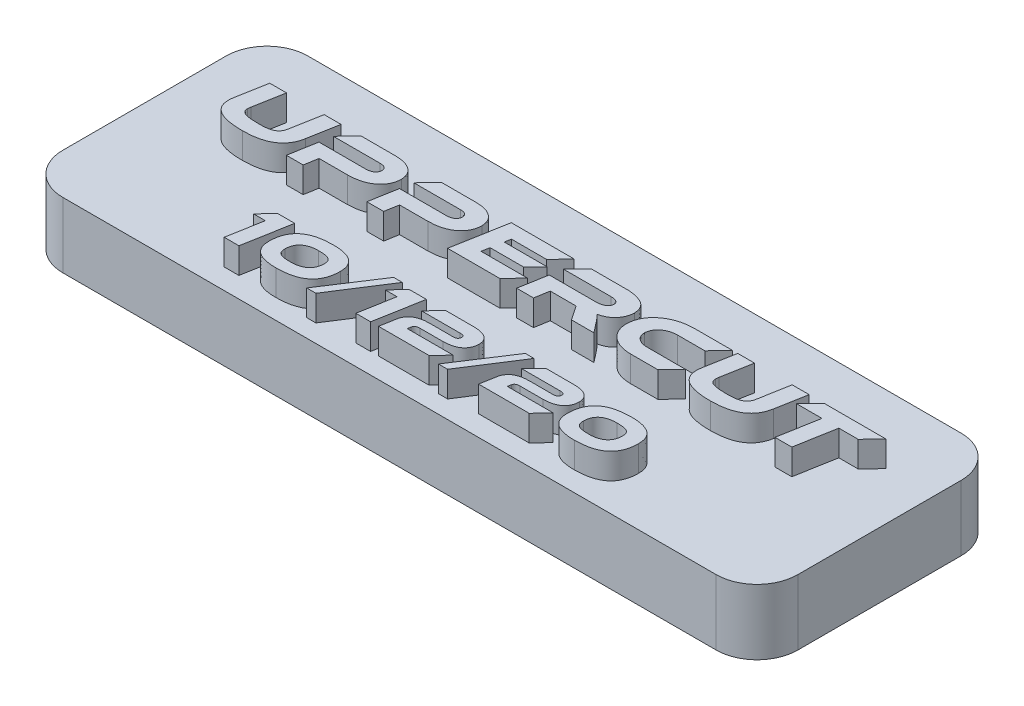
from build123d import *

# Parameters (mm, degrees)
SKETCH1_W           = 57.15
SKETCH1_H           = 19.05
BOSS_EXTRUDE1_DEPTH = 5.08
FILLET1_R           = 3.175
BOSS_EXTRUDE2_DEPTH = 2
SKETCH4_R           = 0.9
CUT_EXTRUDE1_DEPTH  = 4


with BuildPart() as part:
    # Sketch1 → Boss-Extrude1 (new body)
    with BuildSketch(Plane(origin=(0, 0, 0), x_dir=(1, 0, 0), z_dir=(0, 1, 0))):
        Rectangle(SKETCH1_W, SKETCH1_H)
    extrude(amount=BOSS_EXTRUDE1_DEPTH)

    # Fillet1
    fillet1_edges = [part.edges().sort_by_distance(p)[0] for p in [
        (-28.575, 2.54, -9.525),
        (-28.575, 2.54, 9.525),
        (28.575, 2.54, 9.525),
        (28.575, 2.54, -9.525),
    ]]
    fillet(fillet1_edges, radius=FILLET1_R)

    # Sketch3 → Boss-Extrude2 (add)
    with BuildSketch(Plane(origin=(0, 5.08, 0), x_dir=(1, 0, 0), z_dir=(0, 1, 0))):
        Polygon((20.057249805, 4.206347541), (19.008339545, 3.106887389), (20.992422808, 3.106887389), (20.442692732, 0.003655726), (21.750671189, 0.003655726), (22.306720002, 3.106887389), (23.81057929, 3.106887389), (24.859489551, 4.206347541), align=None)
        with BuildLine():
            Line((18.891658067, 4.208766837), (17.577360874, 4.208766837))
            Line((17.577360874, 4.208766837), (17.154005528, 1.862388219))
            add(Edge.make_bspline(
                [(17.154005528, 1.862388219), (17.147281003, 1.827139312), (17.134248218, 1.758823487), (17.105926854, 1.660431879), (17.068621458, 1.570400798), (17.023293564, 1.487363307), (16.969370817, 1.412619114), (16.907483251, 1.344995689), (16.837389946, 1.285307175), (16.758784575, 1.232427909), (16.668968149, 1.187314428), (16.567464703, 1.147991514), (16.452353726, 1.116850242), (16.324747142, 1.090400749), (16.184055726, 1.069568326), (16.030261081, 1.055333672), (15.863418631, 1.047035371), (15.747846354, 1.046819269), (15.687806908, 1.046707005)],
                knots=[0, 0, 0, 0, 0.000107621, 0.000208581, 0.000306536, 0.000399412, 0.000491759, 0.000582339, 0.000673759, 0.000767316, 0.000865846, 0.000974664, 0.001093329, 0.001223132, 0.001365473, 0.001519746, 0.001686326, 0.001866423, 0.001866423, 0.001866423, 0.001866423], degree=3))
            add(Edge.make_bspline(
                [(15.687806908, 1.046707005), (15.61954421, 1.046621121), (15.488478213, 1.046456221), (15.300132462, 1.052429953), (15.128091901, 1.060533552), (14.972635655, 1.075472065), (14.833856541, 1.093422131), (14.711141352, 1.114517759), (14.605260507, 1.141999094), (14.513870158, 1.172526408), (14.436639359, 1.209629908), (14.370477918, 1.251845467), (14.315118863, 1.30043275), (14.270329104, 1.354972316), (14.236848769, 1.415773277), (14.213717712, 1.4824615), (14.201939896, 1.555465653), (14.202181347, 1.605828027), (14.2023057, 1.631765942)],
                knots=[0, 0, 0, 0, 0.000204773, 0.000393168, 0.000565272, 0.000721365, 0.000861515, 0.000985061, 0.001094592, 0.001189417, 0.001273644, 0.00135098, 0.001424164, 0.001493694, 0.001561619, 0.001631293, 0.001704482, 0.001782207, 0.001782207, 0.001782207, 0.001782207], degree=3))
            add(Edge.make_bspline(
                [(14.2023057, 1.631765942), (14.203167723, 1.668081018), (14.204999275, 1.745240135), (14.215790586, 1.821673195), (14.221502947, 1.862132899)],
                knots=[0, 0, 0, 0, 0.00010888, 0.00023134, 0.00023134, 0.00023134, 0.00023134], degree=3))
            Line((14.221502947, 1.862132899), (14.651785871, 4.208766837))
            Line((14.651785871, 4.208766837), (13.343807414, 4.208766837))
            Line((13.343807414, 4.208766837), (12.920452068, 1.862388219))
            add(Edge.make_bspline(
                [(12.920452068, 1.862388219), (12.909111005, 1.795424142), (12.887107618, 1.665503639), (12.883846658, 1.533787249), (12.882266473, 1.46996058)],
                knots=[0, 0, 0, 0, 0.000203453, 0.00039473, 0.00039473, 0.00039473, 0.00039473], degree=3))
            add(Edge.make_bspline(
                [(12.882266473, 1.46996058), (12.883465426, 1.40859245), (12.885799793, 1.289108399), (12.915019258, 1.115562884), (12.96287782, 0.953539335), (13.032605557, 0.803554728), (13.121544547, 0.665184035), (13.232298652, 0.540177804), (13.361331831, 0.425561456), (13.51198711, 0.324145254), (13.68323014, 0.234151547), (13.877038275, 0.15809302), (14.092499451, 0.09238014), (14.330651407, 0.039293588), (14.590705654, -0.002721651), (14.873111411, -0.030740825), (15.177758859, -0.049583047), (15.38854257, -0.051848282), (15.497662754, -0.053020966)],
                knots=[0, 0, 0, 0, 0.000183929, 0.000358111, 0.000526139, 0.000689333, 0.000852629, 0.001017828, 0.001188792, 0.001369069, 0.001561259, 0.001768019, 0.001992702, 0.002236425, 0.002499429, 0.002782504, 0.003087466, 0.003414796, 0.003414796, 0.003414796, 0.003414796], degree=3))
            add(Edge.make_bspline(
                [(15.497662754, -0.053020966), (15.604662871, -0.051404013), (15.812820383, -0.0482584), (16.115843663, -0.025020937), (16.401102472, 0.011650769), (16.668347523, 0.064516757), (16.917764512, 0.131877218), (17.149339744, 0.213665603), (17.362415881, 0.311958663), (17.558152325, 0.424179889), (17.735704839, 0.552059501), (17.896087712, 0.694108361), (18.037551082, 0.852282745), (18.160504477, 1.025501425), (18.266621399, 1.21259616), (18.351802821, 1.415894135), (18.422900101, 1.632639003), (18.452605292, 1.784635018), (18.467751014, 1.862132899)],
                knots=[0, 0, 0, 0, 0.000320974, 0.000624421, 0.000911183, 0.001183331, 0.001441019, 0.001685636, 0.00191919, 0.002144039, 0.002361465, 0.002574487, 0.002785536, 0.002996585, 0.003210663, 0.003429366, 0.003656887, 0.00389357, 0.00389357, 0.00389357, 0.00389357], degree=3))
            Line((18.467751014, 1.862132899), (18.891658067, 4.208766837))
        make_face()
        with BuildLine():
            add(Edge.make_bspline(
                [(9.407795203, 1.105536066), (9.368074173, 1.106368572), (9.290658692, 1.107991107), (9.177831604, 1.120099472), (9.071586611, 1.139341634), (8.971175022, 1.164731953), (8.876642111, 1.197730851), (8.788132018, 1.237674392), (8.705834428, 1.284870974), (8.630029125, 1.338214411), (8.562557887, 1.398892985), (8.502572718, 1.463686553), (8.451815058, 1.534061863), (8.409331276, 1.609307897), (8.376494282, 1.690172386), (8.35268247, 1.775740301), (8.337908849, 1.866215268), (8.334949043, 1.928202108), (8.333433237, 1.95994744)],
                knots=[0, 0, 0, 0, 0.000119146, 0.000232213, 0.000339979, 0.000442857, 0.0005426, 0.00063997, 0.000733741, 0.000826832, 0.000917476, 0.001005473, 0.001091233, 0.001177183, 0.0012641, 0.001352376, 0.001443149, 0.001538437, 0.001538437, 0.001538437, 0.001538437], degree=3))
            add(Edge.make_bspline(
                [(8.333433237, 1.95994744), (8.335810858, 2.00089212), (8.340494794, 2.08155355), (8.364254146, 2.199187811), (8.398735013, 2.311187764), (8.445711454, 2.41754111), (8.505840054, 2.517456178), (8.577264322, 2.612420697), (8.662435349, 2.700160835), (8.757795494, 2.782047564), (8.862822624, 2.855559397), (8.974305121, 2.920673089), (9.092218027, 2.975739929), (9.215828788, 3.021270473), (9.345289436, 3.058247704), (9.480793041, 3.084423964), (9.622301031, 3.10108536), (9.718637033, 3.104537604), (9.767741787, 3.106297295)],
                knots=[0, 0, 0, 0, 0.000122909, 0.000242131, 0.000358943, 0.000473945, 0.00058996, 0.00070807, 0.000829622, 0.000956043, 0.00108463, 0.001213669, 0.001342898, 0.001474501, 0.001608483, 0.001746351, 0.001888089, 0.00203545, 0.00203545, 0.00203545, 0.00203545], degree=3))
            Line((9.767741787, 3.106297295), (11.891058651, 3.106887389))
            Line((11.891058651, 3.106887389), (12.927331438, 4.206347541))
            Line((12.927331438, 4.206347541), (9.963844016, 4.206347541))
            add(Edge.make_bspline(
                [(9.963844016, 4.206347541), (9.861824226, 4.202700375), (9.66201635, 4.195557324), (9.368800436, 4.162353327), (9.08866333, 4.110015155), (8.821802381, 4.036172143), (8.567193621, 3.945267581), (8.32606697, 3.833094278), (8.097425681, 3.702119343), (7.918513148, 3.576781715), (7.782979208, 3.469194079), (7.688901583, 3.383435035), (7.600072042, 3.295964452), (7.517272906, 3.205335074), (7.44177001, 3.110727377), (7.370584227, 3.01426649), (7.308045783, 2.913020304), (7.24987932, 2.809716549), (7.198683996, 2.702914965), (7.154840733, 2.592415367), (7.116682325, 2.479140843), (7.083139219, 2.363167205), (7.058179175, 2.243547853), (7.037481002, 2.121372678), (7.025046341, 1.99550854), (7.020951928, 1.910604524), (7.018878937, 1.867617826)],
                knots=[0, 0, 0, 0, 0.000306166, 0.000599632, 0.000884344, 0.001160233, 0.001429449, 0.00169448, 0.001956971, 0.002218938, 0.002348999, 0.002475859, 0.002600617, 0.002722926, 0.00284385, 0.002963619, 0.003082322, 0.003200591, 0.003319167, 0.003437316, 0.003556997, 0.003677669, 0.003799234, 0.003923371, 0.004049262, 0.004178365, 0.004178365, 0.004178365, 0.004178365], degree=3))
            add(Edge.make_bspline(
                [(7.018878937, 1.867617826), (7.021878811, 1.801688472), (7.02778377, 1.671912941), (7.058234277, 1.482185543), (7.106887393, 1.301387781), (7.173693671, 1.130003576), (7.258701949, 0.967607666), (7.361235998, 0.814264123), (7.483488254, 0.671011828), (7.621719522, 0.536982875), (7.775976027, 0.415938203), (7.943535418, 0.308972587), (8.124241292, 0.218224767), (8.318471195, 0.144692398), (8.524641073, 0.084618858), (8.744475973, 0.042789332), (8.976544208, 0.013380635), (9.135967459, 0.00815489), (9.217420725, 0.005484928)],
                knots=[0, 0, 0, 0, 0.000197872, 0.000389491, 0.000575101, 0.000758611, 0.000940158, 0.001123976, 0.001310786, 0.001504088, 0.001700684, 0.001897981, 0.00209953, 0.002306142, 0.002520237, 0.002742905, 0.002976823, 0.003221191, 0.003221191, 0.003221191, 0.003221191], degree=3))
            Line((9.217420725, 0.005484928), (11.341328575, 0.006075914))
            Line((11.341328575, 0.006075914), (12.371282625, 1.105536066))
            Line((12.371282625, 1.105536066), (9.407795203, 1.105536066))
        make_face()
        with BuildLine():
            add(Edge.make_bspline(
                [(5.727116011, 0.821261664), (5.699329886, 0.855514425), (5.646420316, 0.920737585), (5.572634975, 1.014147602), (5.50403179, 1.094728322), (5.443665698, 1.165931133), (5.387684564, 1.228233858), (5.336180188, 1.283693514), (5.287597305, 1.332710365), (5.25529343, 1.361916294), (5.239934106, 1.375802657)],
                knots=[0, 0, 0, 0, 0.000132319, 0.000251958, 0.000357066, 0.000449775, 0.000531993, 0.000608312, 0.000676831, 0.00073894, 0.00073894, 0.00073894, 0.00073894], degree=3))
            add(Edge.make_bspline(
                [(5.239934106, 1.375802657), (5.290379029, 1.387655917), (5.389711739, 1.41099655), (5.533678759, 1.456505146), (5.66951749, 1.512656797), (5.797487033, 1.577599655), (5.918273639, 1.650662326), (6.029998059, 1.734287933), (6.133735938, 1.827209607), (6.229291405, 1.928008098), (6.315158221, 2.036209783), (6.391371829, 2.148795776), (6.454618099, 2.26744033), (6.508284043, 2.389702633), (6.548786426, 2.517720245), (6.580940206, 2.649747841), (6.598549901, 2.787111939), (6.602681344, 2.88015474), (6.604766908, 2.927122995)],
                knots=[0, 0, 0, 0, 0.000155422, 0.000306047, 0.000452383, 0.000595882, 0.000736201, 0.000875336, 0.001013884, 0.001153561, 0.001291475, 0.00142788, 0.00156081, 0.001694289, 0.00182785, 0.001963107, 0.002101444, 0.002242464, 0.002242464, 0.002242464, 0.002242464], degree=3))
            add(Edge.make_bspline(
                [(6.604766908, 2.927122995), (6.600103261, 2.986733362), (6.591104301, 3.101757358), (6.554698133, 3.266295736), (6.502112492, 3.416602664), (6.431151028, 3.55250609), (6.342622808, 3.674215745), (6.234821065, 3.779555576), (6.111475526, 3.872802597), (5.969843767, 3.946152329), (5.820050119, 4.009923214), (5.665760749, 4.066098529), (5.507642934, 4.111445148), (5.346655301, 4.149301444), (5.182087966, 4.17747869), (5.014545727, 4.196572697), (4.843938234, 4.207081738), (4.729239675, 4.20637971), (4.671329952, 4.206025266)],
                knots=[0, 0, 0, 0, 0.000179195, 0.000345775, 0.000503934, 0.000655634, 0.000804102, 0.000953423, 0.00110627, 0.001266195, 0.001430402, 0.00159465, 0.001758393, 0.001923592, 0.002090563, 0.002258951, 0.002429281, 0.002602973, 0.002602973, 0.002602973, 0.002602973], degree=3))
            Line((4.671329952, 4.206025266), (1.954830316, 4.206347541))
            Line((1.954830316, 4.206347541), (0.905920056, 3.106887389))
            Line((0.905920056, 3.106887389), (4.583424704, 3.106887389))
            add(Edge.make_bspline(
                [(4.583424704, 3.106887389), (4.631386254, 3.105563142), (4.72219801, 3.103055777), (4.850302821, 3.084102014), (4.961923114, 3.053127658), (5.056282687, 3.008361144), (5.132449006, 2.950733271), (5.188185418, 2.878524615), (5.221412081, 2.792039639), (5.225177429, 2.729960255), (5.227135942, 2.697670193)],
                knots=[0, 0, 0, 0, 0.000143839, 0.000272348, 0.000387495, 0.000490117, 0.000583924, 0.00067132, 0.000760449, 0.00085706, 0.00085706, 0.00085706, 0.00085706], degree=3))
            add(Edge.make_bspline(
                [(5.227135942, 2.697670193), (5.225458902, 2.677195647), (5.222150911, 2.636809238), (5.209369674, 2.578009425), (5.189261196, 2.522994029), (5.161870255, 2.47158108), (5.128478879, 2.423095084), (5.086541945, 2.378841184), (5.037523809, 2.338813063), (4.963845594, 2.288346001), (4.859231216, 2.236864834), (4.721752039, 2.191707585), (4.571146602, 2.165412454), (4.466661677, 2.161339559), (4.412624203, 2.15923314)],
                knots=[0, 0, 0, 0, 6.1582e-05, 0.000121471, 0.000179891, 0.000236731, 0.000295819, 0.000355966, 0.000418937, 0.000485369, 0.000623551, 0.000766937, 0.000918284, 0.001080402, 0.001080402, 0.001080402, 0.001080402], degree=3))
            Line((4.412624203, 2.15923314), (0.735314171, 2.159459893))
            Line((0.735314171, 2.159459893), (0.35618998, 0.003655726))
            Line((0.35618998, 0.003655726), (1.664168437, 0.003655726))
            Line((1.664168437, 0.003655726), (1.860049269, 1.11686837))
            Line((1.860049269, 1.11686837), (3.869407478, 1.11686837))
            Line((3.869407478, 1.11686837), (4.615018386, 0.003655726))
            Line((4.615018386, 0.003655726), (6.365308399, 0.003655726))
            Line((6.365308399, 0.003655726), (5.727116011, 0.821261664))
        make_face()
        Polygon((-3.50985548, 1.105536066), (-3.408755696, 1.700326644), (-0.805436255, 1.700326644), (0.104461802, 2.629107706), (-3.238149811, 2.629107706), (-3.149687499, 3.106887389), (-0.413674592, 3.106887389), (0.628916932, 4.206347541), (-4.261785125, 4.206347541), (-5.013714769, 0.006075914), (-0.944448458, 0.006075914), (0.091824329, 1.105536066), align=None)
        with BuildLine():
            add(Edge.make_bspline(
                [(-5.201539614, 2.8527417), (-5.203171033, 2.90231375), (-5.206377568, 2.999746992), (-5.230126313, 3.14197663), (-5.266185061, 3.277108946), (-5.31750117, 3.404564931), (-5.385252325, 3.52306029), (-5.466266126, 3.634253816), (-5.560915861, 3.738655138), (-5.671194718, 3.833025271), (-5.793987305, 3.919798167), (-5.931080963, 3.99434896), (-6.08084461, 4.058920389), (-6.244442992, 4.110009865), (-6.420211472, 4.152486481), (-6.609139471, 4.182135489), (-6.811028504, 4.200187529), (-6.949975131, 4.204039197), (-7.021621401, 4.206025266)],
                knots=[0, 0, 0, 0, 0.000148656, 0.000292181, 0.000431448, 0.000567592, 0.000703091, 0.000839863, 0.000979636, 0.0011248, 0.001274431, 0.001429905, 0.001592071, 0.00176293, 0.001943415, 0.002134132, 0.002336075, 0.002551059, 0.002551059, 0.002551059, 0.002551059], degree=3))
            Line((-7.021621401, 4.206025266), (-9.675205061, 4.206347541))
            Line((-9.675205061, 4.206347541), (-10.736752794, 3.106887389))
            Line((-10.736752794, 3.106887389), (-7.097160566, 3.106887389))
            add(Edge.make_bspline(
                [(-7.097160566, 3.106887389), (-7.053918462, 3.105271439), (-6.972597974, 3.102232508), (-6.858329579, 3.082562512), (-6.76022204, 3.049448147), (-6.678912445, 3.002533217), (-6.615151208, 2.944054673), (-6.568510631, 2.875128596), (-6.54006583, 2.795454755), (-6.536913202, 2.738736187), (-6.535291159, 2.709554203)],
                knots=[0, 0, 0, 0, 0.000129715, 0.000243941, 0.000346575, 0.000438764, 0.000523505, 0.000603877, 0.000686278, 0.000773603, 0.000773603, 0.000773603, 0.000773603], degree=3))
            add(Edge.make_bspline(
                [(-6.535291159, 2.709554203), (-6.536101277, 2.68940885), (-6.537680837, 2.650129607), (-6.546894816, 2.592714955), (-6.562425767, 2.538325425), (-6.584720059, 2.486997986), (-6.612016173, 2.438376615), (-6.64545537, 2.39293274), (-6.685147056, 2.350727054), (-6.746624847, 2.297975724), (-6.837650292, 2.241909704), (-6.964950412, 2.194774305), (-7.110410363, 2.164290223), (-7.214038019, 2.160374672), (-7.26844314, 2.158318986)],
                knots=[0, 0, 0, 0, 6.0445e-05, 0.000117855, 0.000173984, 0.00022968, 0.000285354, 0.000340937, 0.0003985, 0.000458785, 0.000583594, 0.000716696, 0.00086425, 0.001027338, 0.001027338, 0.001027338, 0.001027338], degree=3))
            Line((-7.26844314, 2.158318986), (-10.90735868, 2.158641261))
            Line((-10.90735868, 2.158641261), (-11.28648287, 0.003655726))
            Line((-11.28648287, 0.003655726), (-9.98482315, 0.003655726))
            Line((-9.98482315, 0.003655726), (-9.795261054, 1.059182001))
            Line((-9.795261054, 1.059182001), (-7.583703277, 1.059182001))
            add(Edge.make_bspline(
                [(-7.583703277, 1.059182001), (-7.49346828, 1.061335988), (-7.317746449, 1.065530619), (-7.062379478, 1.093356204), (-6.821270554, 1.132182566), (-6.595931648, 1.189220643), (-6.384588635, 1.259358952), (-6.188669574, 1.345243266), (-6.007477349, 1.445895761), (-5.84262085, 1.561391424), (-5.694686351, 1.688577723), (-5.565839028, 1.826902301), (-5.454680607, 1.973467635), (-5.364889314, 2.131094192), (-5.293673948, 2.29789434), (-5.242829556, 2.47443279), (-5.209911336, 2.660218917), (-5.2043632, 2.787424299), (-5.201539614, 2.8527417)],
                knots=[0, 0, 0, 0, 0.000270666, 0.000527089, 0.000769951, 0.001002752, 0.001223611, 0.001437281, 0.001643542, 0.001844398, 0.002040129, 0.002227698, 0.002410529, 0.002590701, 0.002770513, 0.002953344, 0.003140755, 0.003334978, 0.003334978, 0.003334978, 0.003334978], degree=3))
        make_face()
        with BuildLine():
            add(Edge.make_bspline(
                [(-11.461670242, 2.8527417), (-11.463301661, 2.90231375), (-11.466508196, 2.999746992), (-11.490256941, 3.14197663), (-11.526315689, 3.277108946), (-11.577631798, 3.404564931), (-11.645382953, 3.52306029), (-11.726396754, 3.634253816), (-11.821046489, 3.738655138), (-11.931325346, 3.833025271), (-12.054117933, 3.919798167), (-12.191211591, 3.99434896), (-12.340975238, 4.058920389), (-12.50457362, 4.110009865), (-12.6803421, 4.152486481), (-12.869270099, 4.182135489), (-13.071159132, 4.200187529), (-13.210105759, 4.204039197), (-13.281752029, 4.206025266)],
                knots=[0, 0, 0, 0, 0.000148656, 0.000292181, 0.000431448, 0.000567592, 0.000703091, 0.000839863, 0.000979636, 0.0011248, 0.001274431, 0.001429905, 0.001592071, 0.00176293, 0.001943415, 0.002134132, 0.002336075, 0.002551059, 0.002551059, 0.002551059, 0.002551059], degree=3))
            Line((-13.281752029, 4.206025266), (-15.935335689, 4.206347541))
            Line((-15.935335689, 4.206347541), (-16.996883422, 3.106887389))
            Line((-16.996883422, 3.106887389), (-13.357291194, 3.106887389))
            add(Edge.make_bspline(
                [(-13.357291194, 3.106887389), (-13.31404909, 3.105271439), (-13.232728602, 3.102232508), (-13.118460207, 3.082562512), (-13.020352668, 3.049448147), (-12.939043073, 3.002533217), (-12.875281836, 2.944054673), (-12.828641259, 2.875128596), (-12.800196458, 2.795454755), (-12.79704383, 2.738736187), (-12.795421787, 2.709554203)],
                knots=[0, 0, 0, 0, 0.000129715, 0.000243941, 0.000346575, 0.000438764, 0.000523505, 0.000603877, 0.000686278, 0.000773603, 0.000773603, 0.000773603, 0.000773603], degree=3))
            add(Edge.make_bspline(
                [(-12.795421787, 2.709554203), (-12.796231905, 2.68940885), (-12.797811465, 2.650129607), (-12.807025444, 2.592714955), (-12.822556395, 2.538325425), (-12.844850687, 2.486997986), (-12.872146801, 2.438376615), (-12.905585998, 2.39293274), (-12.945277684, 2.350727054), (-13.006755475, 2.297975724), (-13.09778092, 2.241909704), (-13.22508104, 2.194774305), (-13.370540991, 2.164290223), (-13.474168647, 2.160374672), (-13.528573768, 2.158318986)],
                knots=[0, 0, 0, 0, 6.0445e-05, 0.000117855, 0.000173984, 0.00022968, 0.000285354, 0.000340937, 0.0003985, 0.000458785, 0.000583594, 0.000716696, 0.00086425, 0.001027338, 0.001027338, 0.001027338, 0.001027338], degree=3))
            Line((-13.528573768, 2.158318986), (-17.167489308, 2.158641261))
            Line((-17.167489308, 2.158641261), (-17.546613498, 0.003655726))
            Line((-17.546613498, 0.003655726), (-16.244953778, 0.003655726))
            Line((-16.244953778, 0.003655726), (-16.055391682, 1.059182001))
            Line((-16.055391682, 1.059182001), (-13.843833905, 1.059182001))
            add(Edge.make_bspline(
                [(-13.843833905, 1.059182001), (-13.753598908, 1.061335988), (-13.577877077, 1.065530619), (-13.322510106, 1.093356204), (-13.081401182, 1.132182566), (-12.856062276, 1.189220643), (-12.644719263, 1.259358952), (-12.448800202, 1.345243266), (-12.267607977, 1.445895761), (-12.102751478, 1.561391424), (-11.95481698, 1.688577723), (-11.825969656, 1.826902301), (-11.714811235, 1.973467635), (-11.625019942, 2.131094192), (-11.553804576, 2.29789434), (-11.502960184, 2.47443279), (-11.470041964, 2.660218917), (-11.464493828, 2.787424299), (-11.461670242, 2.8527417)],
                knots=[0, 0, 0, 0, 0.000270666, 0.000527089, 0.000769951, 0.001002752, 0.001223611, 0.001437281, 0.001643542, 0.001844398, 0.002040129, 0.002227698, 0.002410529, 0.002590701, 0.002770513, 0.002953344, 0.003140755, 0.003334978, 0.003334978, 0.003334978, 0.003334978], degree=3))
        make_face()
        with BuildLine():
            Line((-17.499007827, 4.208766837), (-18.81330502, 4.208766837))
            Line((-18.81330502, 4.208766837), (-19.236660366, 1.862388219))
            add(Edge.make_bspline(
                [(-19.236660366, 1.862388219), (-19.24338489, 1.827139312), (-19.256417675, 1.758823487), (-19.28473904, 1.660431879), (-19.322044435, 1.570400798), (-19.36737233, 1.487363307), (-19.421295077, 1.412619114), (-19.483182642, 1.344995689), (-19.553275948, 1.285307175), (-19.631881319, 1.232427909), (-19.721697744, 1.187314428), (-19.82320119, 1.147991514), (-19.938312168, 1.116850242), (-20.065918752, 1.090400749), (-20.206610168, 1.069568326), (-20.360404812, 1.055333672), (-20.527247262, 1.047035371), (-20.642819539, 1.046819269), (-20.702858986, 1.046707005)],
                knots=[0, 0, 0, 0, 0.000107621, 0.000208581, 0.000306536, 0.000399412, 0.000491759, 0.000582339, 0.000673759, 0.000767316, 0.000865846, 0.000974664, 0.001093329, 0.001223132, 0.001365473, 0.001519746, 0.001686326, 0.001866423, 0.001866423, 0.001866423, 0.001866423], degree=3))
            add(Edge.make_bspline(
                [(-20.702858986, 1.046707005), (-20.771121684, 1.046621121), (-20.902187681, 1.046456221), (-21.090533432, 1.052429953), (-21.262573993, 1.060533552), (-21.418030238, 1.075472065), (-21.556809353, 1.093422131), (-21.679524541, 1.114517759), (-21.785405387, 1.141999094), (-21.876795736, 1.172526408), (-21.954026535, 1.209629908), (-22.020187976, 1.251845467), (-22.075547031, 1.30043275), (-22.12033679, 1.354972316), (-22.153817124, 1.415773277), (-22.176948181, 1.4824615), (-22.188725997, 1.555465653), (-22.188484547, 1.605828027), (-22.188360193, 1.631765942)],
                knots=[0, 0, 0, 0, 0.000204773, 0.000393168, 0.000565272, 0.000721365, 0.000861515, 0.000985061, 0.001094592, 0.001189417, 0.001273644, 0.00135098, 0.001424164, 0.001493694, 0.001561619, 0.001631293, 0.001704482, 0.001782207, 0.001782207, 0.001782207, 0.001782207], degree=3))
            add(Edge.make_bspline(
                [(-22.188360193, 1.631765942), (-22.18749817, 1.668081018), (-22.185666619, 1.745240135), (-22.174875308, 1.821673195), (-22.169162947, 1.862132899)],
                knots=[0, 0, 0, 0, 0.00010888, 0.00023134, 0.00023134, 0.00023134, 0.00023134], degree=3))
            Line((-22.169162947, 1.862132899), (-21.738880023, 4.208766837))
            Line((-21.738880023, 4.208766837), (-23.04685848, 4.208766837))
            Line((-23.04685848, 4.208766837), (-23.470213826, 1.862388219))
            add(Edge.make_bspline(
                [(-23.470213826, 1.862388219), (-23.481554888, 1.795424142), (-23.503558276, 1.665503639), (-23.506819236, 1.533787249), (-23.50839942, 1.46996058)],
                knots=[0, 0, 0, 0, 0.000203453, 0.00039473, 0.00039473, 0.00039473, 0.00039473], degree=3))
            add(Edge.make_bspline(
                [(-23.50839942, 1.46996058), (-23.507200468, 1.40859245), (-23.504866101, 1.289108399), (-23.475646636, 1.115562884), (-23.427788074, 0.953539335), (-23.358060336, 0.803554728), (-23.269121347, 0.665184035), (-23.158367242, 0.540177804), (-23.029334063, 0.425561456), (-22.878678784, 0.324145254), (-22.707435754, 0.234151547), (-22.513627618, 0.15809302), (-22.298166442, 0.09238014), (-22.060014487, 0.039293588), (-21.79996024, -0.002721651), (-21.517554483, -0.030740825), (-21.212907034, -0.049583047), (-21.002123323, -0.051848282), (-20.89300314, -0.053020966)],
                knots=[0, 0, 0, 0, 0.000183929, 0.000358111, 0.000526139, 0.000689333, 0.000852629, 0.001017828, 0.001188792, 0.001369069, 0.001561259, 0.001768019, 0.001992702, 0.002236425, 0.002499429, 0.002782504, 0.003087466, 0.003414796, 0.003414796, 0.003414796, 0.003414796], degree=3))
            add(Edge.make_bspline(
                [(-20.89300314, -0.053020966), (-20.786003022, -0.051404013), (-20.577845511, -0.0482584), (-20.27482223, -0.025020937), (-19.989563421, 0.011650769), (-19.722318371, 0.064516757), (-19.472901382, 0.131877218), (-19.24132615, 0.213665603), (-19.028250013, 0.311958663), (-18.832513569, 0.424179889), (-18.654961055, 0.552059501), (-18.494578182, 0.694108361), (-18.353114812, 0.852282745), (-18.230161416, 1.025501425), (-18.124044494, 1.21259616), (-18.038863072, 1.415894135), (-17.967765793, 1.632639003), (-17.938060601, 1.784635018), (-17.922914879, 1.862132899)],
                knots=[0, 0, 0, 0, 0.000320974, 0.000624421, 0.000911183, 0.001183331, 0.001441019, 0.001685636, 0.00191919, 0.002144039, 0.002361465, 0.002574487, 0.002785536, 0.002996585, 0.003210663, 0.003429366, 0.003656887, 0.00389357, 0.00389357, 0.00389357, 0.00389357], degree=3))
            Line((-17.922914879, 1.862132899), (-17.499007827, 4.208766837))
        make_face()
        with BuildLine():
            add(Edge.make_bspline(
                [(13.500579123, -4.205753245), (13.443477767, -4.20639815), (13.331145696, -4.207666832), (13.16543427, -4.213805403), (13.005423483, -4.225246011), (12.850909879, -4.240095428), (12.702015102, -4.260037206), (12.558797757, -4.284920981), (12.420886177, -4.313802188), (12.28833715, -4.346120038), (12.161523241, -4.383749272), (12.040586014, -4.426552533), (11.924563383, -4.472224962), (11.814709109, -4.524117338), (11.709640416, -4.578873484), (11.610624121, -4.638857599), (11.517149486, -4.703243715), (11.429335476, -4.771965987), (11.346477243, -4.844826576), (11.269483602, -4.922821718), (11.197918639, -5.005043307), (11.130509006, -5.090962924), (11.070400246, -5.18251662), (11.013808375, -5.277290921), (10.964642307, -5.377585075), (10.918514335, -5.480915677), (10.87964071, -5.589719203), (10.845259992, -5.702636581), (10.81544899, -5.819692193), (10.792594038, -5.941608197), (10.773994899, -6.06752364), (10.761686051, -6.198094357), (10.753135403, -6.332815699), (10.752420947, -6.424102975), (10.752057742, -6.470510423)],
                knots=[0, 0, 0, 0, 0.000171312, 0.000337012, 0.00049738, 0.000652505, 0.000802621, 0.000947932, 0.001088493, 0.001225264, 0.001357119, 0.001485126, 0.001610044, 0.001730996, 0.001849428, 0.001965345, 0.002078058, 0.002189744, 0.002299681, 0.002408844, 0.002518253, 0.002626572, 0.002736165, 0.002846598, 0.002957491, 0.003071033, 0.00318591, 0.003303822, 0.003425073, 0.003548063, 0.003675777, 0.003806785, 0.003941403, 0.004080604, 0.004080604, 0.004080604, 0.004080604], degree=3))
            add(Edge.make_bspline(
                [(10.752057742, -6.470510423), (10.753415395, -6.532725476), (10.756049135, -6.653417738), (10.781436257, -6.827938058), (10.821959475, -6.990047106), (10.878753854, -7.14024227), (10.952699564, -7.277956037), (11.043260156, -7.403136721), (11.149590467, -7.515956622), (11.27264802, -7.616000774), (11.412134316, -7.702745849), (11.566754139, -7.779438213), (11.737866782, -7.842507446), (11.924425338, -7.895609169), (12.127240747, -7.935791135), (12.345821626, -7.964127031), (12.580330506, -7.98091947), (12.741877245, -7.982880129), (12.82536035, -7.983893345)],
                knots=[0, 0, 0, 0, 0.000186545, 0.000361882, 0.000527754, 0.000687003, 0.000842323, 0.000995285, 0.001149196, 0.001306104, 0.001469661, 0.00164101, 0.001823006, 0.002015943, 0.002222385, 0.002442644, 0.002676813, 0.00292724, 0.00292724, 0.00292724, 0.00292724], degree=3))
            add(Edge.make_bspline(
                [(12.82536035, -7.983893345), (12.882157914, -7.983380019), (12.993655983, -7.98237232), (13.158246816, -7.975990544), (13.317261471, -7.965003258), (13.471116855, -7.948680913), (13.619568795, -7.929266178), (13.762207761, -7.904105738), (13.899474511, -7.875596387), (14.030976125, -7.841995411), (14.157325378, -7.804464931), (14.27786236, -7.761989808), (14.393400638, -7.715814846), (14.503195974, -7.664606669), (14.607173984, -7.608490903), (14.706092622, -7.548339608), (14.799465438, -7.483895632), (14.887174766, -7.414499954), (14.969579615, -7.341424669), (15.045580506, -7.262809113), (15.118169189, -7.18190029), (15.183698345, -7.094705032), (15.244376696, -7.003516426), (15.300787762, -6.908219643), (15.350949963, -6.808134503), (15.395887686, -6.703993625), (15.434979148, -6.595424725), (15.469649433, -6.482622195), (15.497971449, -6.364960314), (15.522207557, -6.243348255), (15.54061351, -6.117331748), (15.552988523, -5.986773695), (15.561464444, -5.851777937), (15.562196605, -5.760225753), (15.562567729, -5.713818961)],
                knots=[0, 0, 0, 0, 0.000170392, 0.000334494, 0.000494064, 0.000648473, 0.00079859, 0.000943113, 0.001082891, 0.001219081, 0.001350169, 0.001478176, 0.001602352, 0.001723304, 0.001841405, 0.001956639, 0.002070464, 0.002181522, 0.00229199, 0.002400592, 0.0025094, 0.002617866, 0.002727459, 0.002837893, 0.002949859, 0.003063082, 0.00317796, 0.003295871, 0.003416929, 0.003540857, 0.00366778, 0.003798788, 0.003934205, 0.004073405, 0.004073405, 0.004073405, 0.004073405], degree=3))
            add(Edge.make_bspline(
                [(15.562567729, -5.713818961), (15.561226074, -5.651864372), (15.558617943, -5.53142685), (15.532905379, -5.357329546), (15.493717893, -5.194951682), (15.436692426, -5.045253766), (15.363324309, -4.907894424), (15.274069208, -4.782830639), (15.167964402, -4.670804764), (15.046343598, -4.570938519), (14.907795488, -4.484275151), (14.753605793, -4.409545186), (14.583727588, -4.345204255), (14.397800187, -4.293863202), (14.195869017, -4.25419887), (13.978407382, -4.225768444), (13.744693741, -4.209016704), (13.58367987, -4.207051109), (13.500579123, -4.205753245)],
                knots=[0, 0, 0, 0, 0.000185746, 0.000361083, 0.00052676, 0.000686009, 0.000840246, 0.000992741, 0.001145521, 0.00130181, 0.001463587, 0.001634583, 0.001815083, 0.002007802, 0.002212518, 0.002431984, 0.002665356, 0.002914983, 0.002914983, 0.002914983, 0.002914983], degree=3))
        make_face()
        with BuildLine():
            add(Edge.make_bspline(
                [(12.991920834, -7.021348599), (12.945727754, -7.021854174), (12.856573219, -7.022829956), (12.727658224, -7.017591194), (12.608312761, -7.009340097), (12.498551662, -6.995853431), (12.39828762, -6.977791428), (12.307744287, -6.954558851), (12.226405062, -6.92776808), (12.154197246, -6.89577873), (12.090205884, -6.85746675), (12.036179313, -6.809228041), (11.989609601, -6.753532905), (11.95305929, -6.688452997), (11.923924225, -6.615916979), (11.904463421, -6.534816355), (11.892151266, -6.445830998), (11.891455672, -6.383634321), (11.89109436, -6.351327518)],
                knots=[0, 0, 0, 0, 0.000138565, 0.000267436, 0.000386943, 0.000497368, 0.000599032, 0.000692348, 0.000777591, 0.00085564, 0.000928899, 0.001000308, 0.001071897, 0.001145712, 0.001223247, 0.001305698, 0.001395292, 0.001492131, 0.001492131, 0.001492131, 0.001492131], degree=3))
            add(Edge.make_bspline(
                [(11.89109436, -6.351327518), (11.892631213, -6.304070169), (11.8956213, -6.212126705), (11.91428324, -6.079013736), (11.943538683, -5.954439253), (11.985356502, -5.839274516), (12.03741413, -5.731825667), (12.102624352, -5.634468641), (12.178440222, -5.545120744), (12.266385769, -5.466071948), (12.364358845, -5.395226287), (12.472961323, -5.334487382), (12.591341859, -5.283435533), (12.718935465, -5.240941797), (12.856268436, -5.208296683), (13.003138297, -5.185693562), (13.159672515, -5.170762309), (13.267393832, -5.169135367), (13.322888986, -5.16829721)],
                knots=[0, 0, 0, 0, 0.000141763, 0.000275812, 0.0004025, 0.000524963, 0.000642655, 0.000759791, 0.000875529, 0.00099331, 0.001113634, 0.001237554, 0.001365798, 0.001499859, 0.001640517, 0.001788722, 0.001945363, 0.002111808, 0.002111808, 0.002111808, 0.002111808], degree=3))
            add(Edge.make_bspline(
                [(13.322888986, -5.16829721), (13.369017635, -5.168009724), (13.458095955, -5.167454564), (13.587246267, -5.171313587), (13.706857399, -5.17974049), (13.816794485, -5.193477036), (13.917087693, -5.210588071), (14.007799449, -5.232796313), (14.088993751, -5.25982086), (14.161278539, -5.291687778), (14.224904132, -5.330152418), (14.279299498, -5.377160874), (14.324886794, -5.432670471), (14.361811337, -5.496790682), (14.390660652, -5.569240936), (14.410087678, -5.650050065), (14.422523204, -5.738759012), (14.423185583, -5.80069376), (14.423531111, -5.833001866)],
                knots=[0, 0, 0, 0, 0.00013838, 0.000267224, 0.000387529, 0.000497953, 0.000599476, 0.000692596, 0.00077784, 0.000855889, 0.000929147, 0.001000031, 0.001070493, 0.001143616, 0.001221151, 0.001303602, 0.001392403, 0.001489242, 0.001489242, 0.001489242, 0.001489242], degree=3))
            add(Edge.make_bspline(
                [(14.423531111, -5.833001866), (14.421993591, -5.880258006), (14.419002207, -5.972199119), (14.400313372, -6.105585977), (14.370952423, -6.230260661), (14.330249758, -6.346409008), (14.277247601, -6.453739693), (14.211830339, -6.551573704), (14.136186329, -6.64153852), (14.048544329, -6.721564153), (13.950129382, -6.791879743), (13.842584497, -6.854243117), (13.724035159, -6.904835069), (13.596395026, -6.947243215), (13.459199853, -6.980841995), (13.312098289, -7.004512108), (13.15520754, -7.019068958), (13.04722791, -7.020761541), (12.991920834, -7.021348599)],
                knots=[0, 0, 0, 0, 0.000141763, 0.000275812, 0.000403278, 0.000525472, 0.000644235, 0.000761371, 0.000877718, 0.000996039, 0.001116363, 0.001239983, 0.001368227, 0.001502288, 0.001643134, 0.001791467, 0.001948904, 0.002115349, 0.002115349, 0.002115349, 0.002115349], degree=3))
        make_face(mode=Mode.SUBTRACT)
        with BuildLine():
            Line((5.969282838, -5.218973535), (8.960414732, -5.218973535))
            add(Edge.make_bspline(
                [(8.960414732, -5.218973535), (8.988115646, -5.218922741), (9.039962021, -5.218827674), (9.112691024, -5.225918073), (9.174215065, -5.242216387), (9.226045602, -5.26353583), (9.266138991, -5.294908436), (9.294452991, -5.334273792), (9.312004968, -5.381008794), (9.313229668, -5.4147712), (9.313864034, -5.432259348)],
                knots=[0, 0, 0, 0, 8.3099e-05, 0.000155531, 0.000218392, 0.000273538, 0.000322508, 0.000368908, 0.000417497, 0.000469711, 0.000469711, 0.000469711, 0.000469711], degree=3))
            add(Edge.make_bspline(
                [(9.313864034, -5.432259348), (9.31322424, -5.458018948), (9.312014636, -5.506720508), (9.29145225, -5.573936821), (9.258165874, -5.630194031), (9.208952251, -5.673414306), (9.145421152, -5.704561408), (9.067686985, -5.726311626), (8.974561826, -5.738498194), (8.907560181, -5.73961472), (8.871527482, -5.740215175)],
                knots=[0, 0, 0, 0, 7.6993e-05, 0.000145564, 0.000208395, 0.000270703, 0.000339032, 0.00041902, 0.000511893, 0.000619952, 0.000619952, 0.000619952, 0.000619952], degree=3))
            Line((8.871527482, -5.740215175), (7.113763988, -5.739416071))
            add(Edge.make_bspline(
                [(7.113763988, -5.739416071), (7.058161832, -5.740560639), (6.94990867, -5.742789025), (6.791913343, -5.753609346), (6.643193984, -5.772857955), (6.503571116, -5.798779792), (6.373307918, -5.833149331), (6.252229066, -5.875619954), (6.139961685, -5.92500466), (6.036759818, -5.98174212), (5.943290621, -6.047028209), (5.858765128, -6.120143527), (5.783364519, -6.201107035), (5.717363497, -6.289606037), (5.660981923, -6.385733808), (5.613886169, -6.489539314), (5.574938805, -6.600822081), (5.55761713, -6.678800473), (5.548804088, -6.718474855)],
                knots=[0, 0, 0, 0, 0.000166829, 0.000324804, 0.000474816, 0.000616477, 0.000750546, 0.000878553, 0.001001026, 0.001118108, 0.001231277, 0.001342418, 0.001452782, 0.001562526, 0.00167296, 0.001786425, 0.001904052, 0.002025887, 0.002025887, 0.002025887, 0.002025887], degree=3))
            Line((5.548804088, -6.718474855), (5.333459977, -7.932183575))
            Line((5.333459977, -7.932183575), (9.270032821, -7.932183575))
            Line((9.270032821, -7.932183575), (10.17677151, -6.970155942))
            Line((10.17677151, -6.970155942), (6.605105699, -6.970155942))
            Line((6.605105699, -6.970155942), (6.654865749, -6.707239748))
            add(Edge.make_bspline(
                [(6.654865749, -6.707239748), (6.658643273, -6.686112106), (6.66596603, -6.645156023), (6.694677383, -6.590591717), (6.733038076, -6.543848716), (6.784377407, -6.508043577), (6.845452874, -6.47963759), (6.917770494, -6.461031101), (7.000833915, -6.450993538), (7.059757426, -6.450679637), (7.09098288, -6.450513291)],
                knots=[0, 0, 0, 0, 6.4036e-05, 0.000124134, 0.000182613, 0.000243892, 0.000310094, 0.000383827, 0.000466868, 0.000560486, 0.000560486, 0.000560486, 0.000560486], degree=3))
            Line((7.09098288, -6.450513291), (8.849836843, -6.449714187))
            add(Edge.make_bspline(
                [(8.849836843, -6.449714187), (8.915517868, -6.448593152), (9.042852309, -6.446419826), (9.226750158, -6.426694059), (9.398166768, -6.400940141), (9.556013654, -6.361961645), (9.701767648, -6.315052912), (9.833108903, -6.255202462), (9.952582018, -6.187512089), (10.057294458, -6.107690588), (10.14987765, -6.020066732), (10.230334011, -5.925525662), (10.298112896, -5.823724541), (10.353865698, -5.715194429), (10.396001667, -5.599220599), (10.426697103, -5.476792913), (10.444352448, -5.347458364), (10.446305402, -5.259004345), (10.447301455, -5.21389067)],
                knots=[0, 0, 0, 0, 0.00019697, 0.000381861, 0.000554393, 0.000716581, 0.000869107, 0.001013024, 0.00114885, 0.001280192, 0.001406932, 0.001530654, 0.001651783, 0.001773055, 0.001895792, 0.002021116, 0.002151095, 0.002286391, 0.002286391, 0.002286391, 0.002286391], degree=3))
            add(Edge.make_bspline(
                [(10.447301455, -5.21389067), (10.446849001, -5.1780961), (10.445963256, -5.108023129), (10.429753409, -5.005989197), (10.405761336, -4.909275966), (10.369226633, -4.818686266), (10.32159228, -4.734234215), (10.263513238, -4.655338408), (10.195145611, -4.582231577), (10.115851171, -4.515185386), (10.025028254, -4.455053695), (9.921449634, -4.402688892), (9.805216513, -4.359688685), (9.677029034, -4.322394884), (9.536226025, -4.294289614), (9.38287898, -4.27367202), (9.217012449, -4.26108405), (9.102182833, -4.258543735), (9.042702929, -4.257227893)],
                knots=[0, 0, 0, 0, 0.000107259, 0.000209975, 0.000309113, 0.00040566, 0.000501999, 0.00059927, 0.000698874, 0.0008016, 0.000910084, 0.001024914, 0.001148961, 0.001281358, 0.001425053, 0.00157924, 0.00174531, 0.001923772, 0.001923772, 0.001923772, 0.001923772], degree=3))
            Line((9.042702929, -4.257227893), (6.876021527, -4.256945902))
            Line((6.876021527, -4.256945902), (5.969282838, -5.218973535))
        make_face()
        Polygon((5.083472397, -4.05005839), (2.418545275, -8.139071868), (3.131772658, -8.139071868), (5.757997519, -4.05005839), align=None)
        with BuildLine():
            Line((-1.812001027, -5.218973535), (1.179130867, -5.218973535))
            add(Edge.make_bspline(
                [(1.179130867, -5.218973535), (1.206831781, -5.218922741), (1.258678156, -5.218827674), (1.331407159, -5.225918073), (1.392931201, -5.242216387), (1.444761737, -5.26353583), (1.484855127, -5.294908436), (1.513169126, -5.334273792), (1.530721104, -5.381008794), (1.531945803, -5.4147712), (1.532580169, -5.432259348)],
                knots=[0, 0, 0, 0, 8.3099e-05, 0.000155531, 0.000218392, 0.000273538, 0.000322508, 0.000368908, 0.000417497, 0.000469711, 0.000469711, 0.000469711, 0.000469711], degree=3))
            add(Edge.make_bspline(
                [(1.532580169, -5.432259348), (1.531940376, -5.458018948), (1.530730771, -5.506720508), (1.510168385, -5.573936821), (1.476882009, -5.630194031), (1.427668386, -5.673414306), (1.364137287, -5.704561408), (1.286403121, -5.726311626), (1.193277961, -5.738498194), (1.126276316, -5.73961472), (1.090243617, -5.740215175)],
                knots=[0, 0, 0, 0, 7.6993e-05, 0.000145564, 0.000208395, 0.000270703, 0.000339032, 0.00041902, 0.000511893, 0.000619952, 0.000619952, 0.000619952, 0.000619952], degree=3))
            Line((1.090243617, -5.740215175), (-0.667519877, -5.739416071))
            add(Edge.make_bspline(
                [(-0.667519877, -5.739416071), (-0.723122033, -5.740560639), (-0.831375195, -5.742789025), (-0.989370521, -5.753609346), (-1.138089881, -5.772857955), (-1.277712749, -5.798779792), (-1.407975947, -5.833149331), (-1.529054799, -5.875619954), (-1.641322179, -5.92500466), (-1.744524047, -5.98174212), (-1.837993244, -6.047028209), (-1.922518737, -6.120143527), (-1.997919346, -6.201107035), (-2.063920368, -6.289606037), (-2.120301941, -6.385733808), (-2.167397696, -6.489539314), (-2.206345059, -6.600822081), (-2.223666735, -6.678800473), (-2.232479777, -6.718474855)],
                knots=[0, 0, 0, 0, 0.000166829, 0.000324804, 0.000474816, 0.000616477, 0.000750546, 0.000878553, 0.001001026, 0.001118108, 0.001231277, 0.001342418, 0.001452782, 0.001562526, 0.00167296, 0.001786425, 0.001904052, 0.002025887, 0.002025887, 0.002025887, 0.002025887], degree=3))
            Line((-2.232479777, -6.718474855), (-2.447823888, -7.932183575))
            Line((-2.447823888, -7.932183575), (1.488748956, -7.932183575))
            Line((1.488748956, -7.932183575), (2.395487645, -6.970155942))
            Line((2.395487645, -6.970155942), (-1.176178166, -6.970155942))
            Line((-1.176178166, -6.970155942), (-1.126418116, -6.707239748))
            add(Edge.make_bspline(
                [(-1.126418116, -6.707239748), (-1.122640592, -6.686112106), (-1.115317835, -6.645156023), (-1.086606482, -6.590591717), (-1.048245789, -6.543848716), (-0.996906457, -6.508043577), (-0.935830991, -6.47963759), (-0.863513371, -6.461031101), (-0.78044995, -6.450993538), (-0.721526439, -6.450679637), (-0.690300984, -6.450513291)],
                knots=[0, 0, 0, 0, 6.4036e-05, 0.000124134, 0.000182613, 0.000243892, 0.000310094, 0.000383827, 0.000466868, 0.000560486, 0.000560486, 0.000560486, 0.000560486], degree=3))
            Line((-0.690300984, -6.450513291), (1.068552978, -6.449714187))
            add(Edge.make_bspline(
                [(1.068552978, -6.449714187), (1.134234004, -6.448593152), (1.261568444, -6.446419826), (1.445466293, -6.426694059), (1.616882903, -6.400940141), (1.774729789, -6.361961645), (1.920483783, -6.315052912), (2.051825038, -6.255202462), (2.171298153, -6.187512089), (2.276010593, -6.107690588), (2.368593785, -6.020066732), (2.449050147, -5.925525662), (2.516829031, -5.823724541), (2.572581833, -5.715194429), (2.614717803, -5.599220599), (2.645413239, -5.476792913), (2.663068584, -5.347458364), (2.665021537, -5.259004345), (2.666017591, -5.21389067)],
                knots=[0, 0, 0, 0, 0.00019697, 0.000381861, 0.000554393, 0.000716581, 0.000869107, 0.001013024, 0.00114885, 0.001280192, 0.001406932, 0.001530654, 0.001651783, 0.001773055, 0.001895792, 0.002021116, 0.002151095, 0.002286391, 0.002286391, 0.002286391, 0.002286391], degree=3))
            add(Edge.make_bspline(
                [(2.666017591, -5.21389067), (2.665565136, -5.1780961), (2.664679391, -5.108023129), (2.648469544, -5.005989197), (2.624477471, -4.909275966), (2.587942768, -4.818686266), (2.540308415, -4.734234215), (2.482229373, -4.655338408), (2.413861747, -4.582231577), (2.334567307, -4.515185386), (2.24374439, -4.455053695), (2.140165769, -4.402688892), (2.023932649, -4.359688685), (1.895745169, -4.322394884), (1.754942161, -4.294289614), (1.601595115, -4.27367202), (1.435728584, -4.26108405), (1.320898968, -4.258543735), (1.261419064, -4.257227893)],
                knots=[0, 0, 0, 0, 0.000107259, 0.000209975, 0.000309113, 0.00040566, 0.000501999, 0.00059927, 0.000698874, 0.0008016, 0.000910084, 0.001024914, 0.001148961, 0.001281358, 0.001425053, 0.00157924, 0.00174531, 0.001923772, 0.001923772, 0.001923772, 0.001923772], degree=3))
            Line((1.261419064, -4.257227893), (-0.905262338, -4.256945902))
            Line((-0.905262338, -4.256945902), (-1.812001027, -5.218973535))
        make_face()
        Polygon((-4.623097808, -5.218973535), (-3.721888013, -5.218973535), (-4.20290183, -7.93430124), (-3.05842068, -7.93430124), (-2.400482241, -4.256945902), (-3.75506138, -4.256945902), align=None)
        Polygon((-5.155059004, -4.05005839), (-7.819986126, -8.139071868), (-7.106758743, -8.139071868), (-4.480533882, -4.05005839), align=None)
        with BuildLine():
            add(Edge.make_bspline(
                [(-9.6896945, -4.205753245), (-9.746795857, -4.20639815), (-9.859127927, -4.207666832), (-10.024839353, -4.213805403), (-10.184850141, -4.225246011), (-10.339363744, -4.240095428), (-10.488258521, -4.260037206), (-10.631475866, -4.284920981), (-10.769387446, -4.313802188), (-10.901936473, -4.346120038), (-11.028750382, -4.383749272), (-11.14968761, -4.426552533), (-11.26571024, -4.472224962), (-11.375564514, -4.524117338), (-11.480633207, -4.578873484), (-11.579649502, -4.638857599), (-11.673124137, -4.703243715), (-11.760938147, -4.771965987), (-11.84379638, -4.844826576), (-11.920790021, -4.922821718), (-11.992354985, -5.005043307), (-12.059764617, -5.090962924), (-12.119873377, -5.18251662), (-12.176465248, -5.277290921), (-12.225631317, -5.377585075), (-12.271759288, -5.480915677), (-12.310632914, -5.589719203), (-12.345013631, -5.702636581), (-12.374824633, -5.819692193), (-12.397679586, -5.941608197), (-12.416278725, -6.06752364), (-12.428587572, -6.198094357), (-12.43713822, -6.332815699), (-12.437852676, -6.424102975), (-12.438215882, -6.470510423)],
                knots=[0, 0, 0, 0, 0.000171312, 0.000337012, 0.00049738, 0.000652505, 0.000802621, 0.000947932, 0.001088493, 0.001225264, 0.001357119, 0.001485126, 0.001610044, 0.001730996, 0.001849428, 0.001965345, 0.002078058, 0.002189744, 0.002299681, 0.002408844, 0.002518253, 0.002626572, 0.002736165, 0.002846598, 0.002957491, 0.003071033, 0.00318591, 0.003303822, 0.003425073, 0.003548063, 0.003675777, 0.003806785, 0.003941403, 0.004080604, 0.004080604, 0.004080604, 0.004080604], degree=3))
            add(Edge.make_bspline(
                [(-12.438215882, -6.470510423), (-12.436858228, -6.532725476), (-12.434224488, -6.653417738), (-12.408837366, -6.827938058), (-12.368314148, -6.990047106), (-12.311519769, -7.14024227), (-12.237574059, -7.277956037), (-12.147013467, -7.403136721), (-12.040683156, -7.515956622), (-11.917625603, -7.616000774), (-11.778139308, -7.702745849), (-11.623519484, -7.779438213), (-11.452406842, -7.842507446), (-11.265848286, -7.895609169), (-11.063032876, -7.935791135), (-10.844451997, -7.964127031), (-10.609943117, -7.98091947), (-10.448396379, -7.982880129), (-10.364913273, -7.983893345)],
                knots=[0, 0, 0, 0, 0.000186545, 0.000361882, 0.000527754, 0.000687003, 0.000842323, 0.000995285, 0.001149196, 0.001306104, 0.001469661, 0.00164101, 0.001823006, 0.002015943, 0.002222385, 0.002442644, 0.002676813, 0.00292724, 0.00292724, 0.00292724, 0.00292724], degree=3))
            add(Edge.make_bspline(
                [(-10.364913273, -7.983893345), (-10.308115709, -7.983380019), (-10.19661764, -7.98237232), (-10.032026807, -7.975990544), (-9.873012152, -7.965003258), (-9.719156769, -7.948680913), (-9.570704828, -7.929266178), (-9.428065862, -7.904105738), (-9.290799112, -7.875596387), (-9.159297498, -7.841995411), (-9.032948245, -7.804464931), (-8.912411263, -7.761989808), (-8.796872986, -7.715814846), (-8.687077649, -7.664606669), (-8.583099639, -7.608490903), (-8.484181001, -7.548339608), (-8.390808185, -7.483895632), (-8.303098857, -7.414499954), (-8.220694008, -7.341424669), (-8.144693117, -7.262809113), (-8.072104434, -7.18190029), (-8.006575278, -7.094705032), (-7.945896927, -7.003516426), (-7.889485861, -6.908219643), (-7.83932366, -6.808134503), (-7.794385937, -6.703993625), (-7.755294475, -6.595424725), (-7.72062419, -6.482622195), (-7.692302174, -6.364960314), (-7.668066066, -6.243348255), (-7.649660113, -6.117331748), (-7.6372851, -5.986773695), (-7.628809179, -5.851777937), (-7.628077018, -5.760225753), (-7.627705894, -5.713818961)],
                knots=[0, 0, 0, 0, 0.000170392, 0.000334494, 0.000494064, 0.000648473, 0.00079859, 0.000943113, 0.001082891, 0.001219081, 0.001350169, 0.001478176, 0.001602352, 0.001723304, 0.001841405, 0.001956639, 0.002070464, 0.002181522, 0.00229199, 0.002400592, 0.0025094, 0.002617866, 0.002727459, 0.002837893, 0.002949859, 0.003063082, 0.00317796, 0.003295871, 0.003416929, 0.003540857, 0.00366778, 0.003798788, 0.003934205, 0.004073405, 0.004073405, 0.004073405, 0.004073405], degree=3))
            add(Edge.make_bspline(
                [(-7.627705894, -5.713818961), (-7.629047549, -5.651864372), (-7.63165568, -5.53142685), (-7.657368244, -5.357329546), (-7.69655573, -5.194951682), (-7.753581197, -5.045253766), (-7.826949314, -4.907894424), (-7.916204415, -4.782830639), (-8.022309221, -4.670804764), (-8.143930025, -4.570938519), (-8.282478135, -4.484275151), (-8.43666783, -4.409545186), (-8.606546035, -4.345204255), (-8.792473436, -4.293863202), (-8.994404606, -4.25419887), (-9.211866241, -4.225768444), (-9.445579882, -4.209016704), (-9.606593753, -4.207051109), (-9.6896945, -4.205753245)],
                knots=[0, 0, 0, 0, 0.000185746, 0.000361083, 0.00052676, 0.000686009, 0.000840246, 0.000992741, 0.001145521, 0.00130181, 0.001463587, 0.001634583, 0.001815083, 0.002007802, 0.002212518, 0.002431984, 0.002665356, 0.002914983, 0.002914983, 0.002914983, 0.002914983], degree=3))
        make_face()
        with BuildLine():
            add(Edge.make_bspline(
                [(-10.198352789, -7.021348599), (-10.244545869, -7.021854174), (-10.333700404, -7.022829956), (-10.462615399, -7.017591194), (-10.581960862, -7.009340097), (-10.691721961, -6.995853431), (-10.791986003, -6.977791428), (-10.882529336, -6.954558851), (-10.963868561, -6.92776808), (-11.036076377, -6.89577873), (-11.100067739, -6.85746675), (-11.15409431, -6.809228041), (-11.200664022, -6.753532905), (-11.237214333, -6.688452997), (-11.266349398, -6.615916979), (-11.285810202, -6.534816355), (-11.298122357, -6.445830998), (-11.298817951, -6.383634321), (-11.299179263, -6.351327518)],
                knots=[0, 0, 0, 0, 0.000138565, 0.000267436, 0.000386943, 0.000497368, 0.000599032, 0.000692348, 0.000777591, 0.00085564, 0.000928899, 0.001000308, 0.001071897, 0.001145712, 0.001223247, 0.001305698, 0.001395292, 0.001492131, 0.001492131, 0.001492131, 0.001492131], degree=3))
            add(Edge.make_bspline(
                [(-11.299179263, -6.351327518), (-11.29764241, -6.304070169), (-11.294652323, -6.212126705), (-11.275990383, -6.079013736), (-11.24673494, -5.954439253), (-11.204917121, -5.839274516), (-11.152859493, -5.731825667), (-11.087649271, -5.634468641), (-11.011833401, -5.545120744), (-10.923887854, -5.466071948), (-10.825914778, -5.395226287), (-10.7173123, -5.334487382), (-10.598931765, -5.283435533), (-10.471338158, -5.240941797), (-10.334005187, -5.208296683), (-10.187135326, -5.185693562), (-10.030601108, -5.170762309), (-9.922879791, -5.169135367), (-9.867384638, -5.16829721)],
                knots=[0, 0, 0, 0, 0.000141763, 0.000275812, 0.0004025, 0.000524963, 0.000642655, 0.000759791, 0.000875529, 0.00099331, 0.001113634, 0.001237554, 0.001365798, 0.001499859, 0.001640517, 0.001788722, 0.001945363, 0.002111808, 0.002111808, 0.002111808, 0.002111808], degree=3))
            add(Edge.make_bspline(
                [(-9.867384638, -5.16829721), (-9.821255989, -5.168009724), (-9.732177669, -5.167454564), (-9.603027356, -5.171313587), (-9.483416224, -5.17974049), (-9.373479138, -5.193477036), (-9.27318593, -5.210588071), (-9.182474175, -5.232796313), (-9.101279872, -5.25982086), (-9.028995084, -5.291687778), (-8.965369491, -5.330152418), (-8.910974125, -5.377160874), (-8.865386829, -5.432670471), (-8.828462286, -5.496790682), (-8.799612971, -5.569240936), (-8.780185946, -5.650050065), (-8.767750419, -5.738759012), (-8.76708804, -5.80069376), (-8.766742512, -5.833001866)],
                knots=[0, 0, 0, 0, 0.00013838, 0.000267224, 0.000387529, 0.000497953, 0.000599476, 0.000692596, 0.00077784, 0.000855889, 0.000929147, 0.001000031, 0.001070493, 0.001143616, 0.001221151, 0.001303602, 0.001392403, 0.001489242, 0.001489242, 0.001489242, 0.001489242], degree=3))
            add(Edge.make_bspline(
                [(-8.766742512, -5.833001866), (-8.768280032, -5.880258006), (-8.771271416, -5.972199119), (-8.789960251, -6.105585977), (-8.819321201, -6.230260661), (-8.860023865, -6.346409008), (-8.913026023, -6.453739693), (-8.978443284, -6.551573704), (-9.054087294, -6.64153852), (-9.141729294, -6.721564153), (-9.240144241, -6.791879743), (-9.347689126, -6.854243117), (-9.466238465, -6.904835069), (-9.593878597, -6.947243215), (-9.73107377, -6.980841995), (-9.878175334, -7.004512108), (-10.035066083, -7.019068958), (-10.143045714, -7.020761541), (-10.198352789, -7.021348599)],
                knots=[0, 0, 0, 0, 0.000141763, 0.000275812, 0.000403278, 0.000525472, 0.000644235, 0.000761371, 0.000877718, 0.000996039, 0.001116363, 0.001239983, 0.001368227, 0.001502288, 0.001643134, 0.001791467, 0.001948904, 0.002115349, 0.002115349, 0.002115349, 0.002115349], degree=3))
        make_face(mode=Mode.SUBTRACT)
        Polygon((-14.861629209, -5.218973535), (-13.960419414, -5.218973535), (-14.441433231, -7.93430124), (-13.296952081, -7.93430124), (-12.639013642, -4.256945902), (-13.993592781, -4.256945902), align=None)
    extrude(amount=BOSS_EXTRUDE2_DEPTH)

    # Sketch4 → Cut-Extrude1 (cut)
    with BuildSketch(Plane.XZ):
        with Locations((-25.4, 0)):
            Circle(SKETCH4_R)
        with Locations((25.4, 0)):
            Circle(SKETCH4_R)
    extrude(amount=-CUT_EXTRUDE1_DEPTH, mode=Mode.SUBTRACT)


solid = part.part
